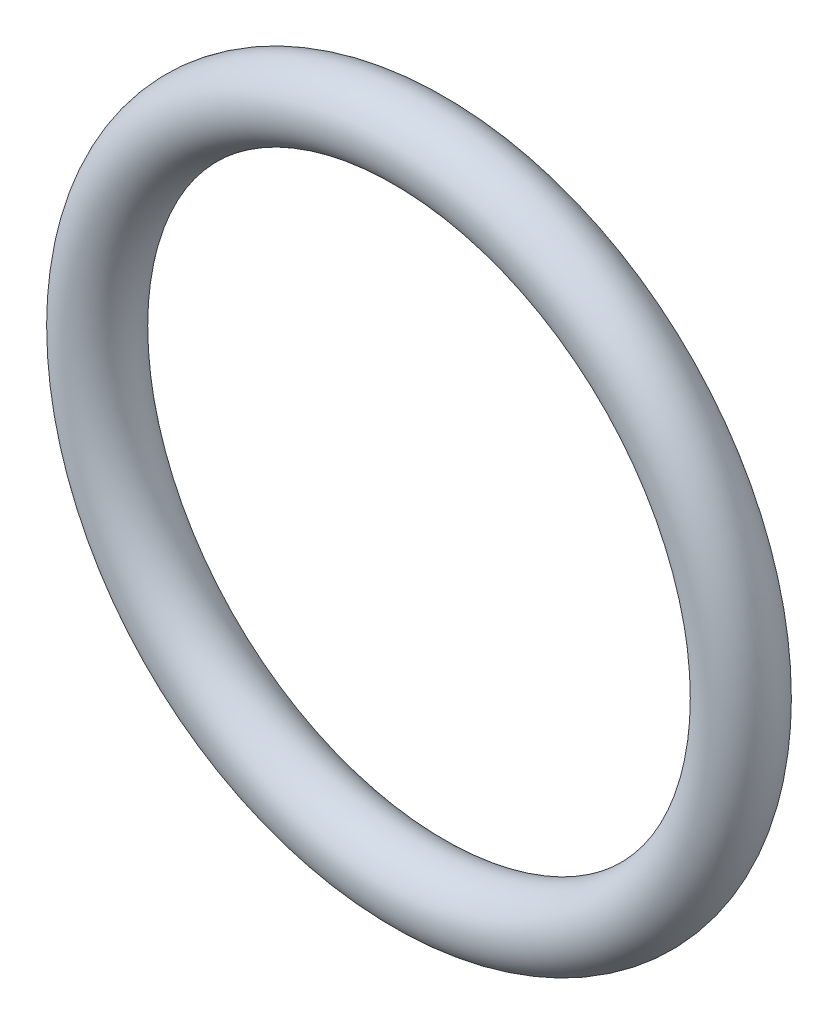
from build123d import *

# Parameters (mm, degrees)
SKETCH1_R = 0.75


with BuildPart() as part:
    # Sketch1 → Revolve1 (revolve)
    with BuildSketch(Plane(origin=(0, 0, 0), x_dir=(1, 0, 0), z_dir=(0, 1, 0))):
        with Locations((6.75, -36.9)):
            Circle(SKETCH1_R)
    revolve(axis=Axis((0, 0, 36.15), (0, 0, 1)))


solid = part.part
